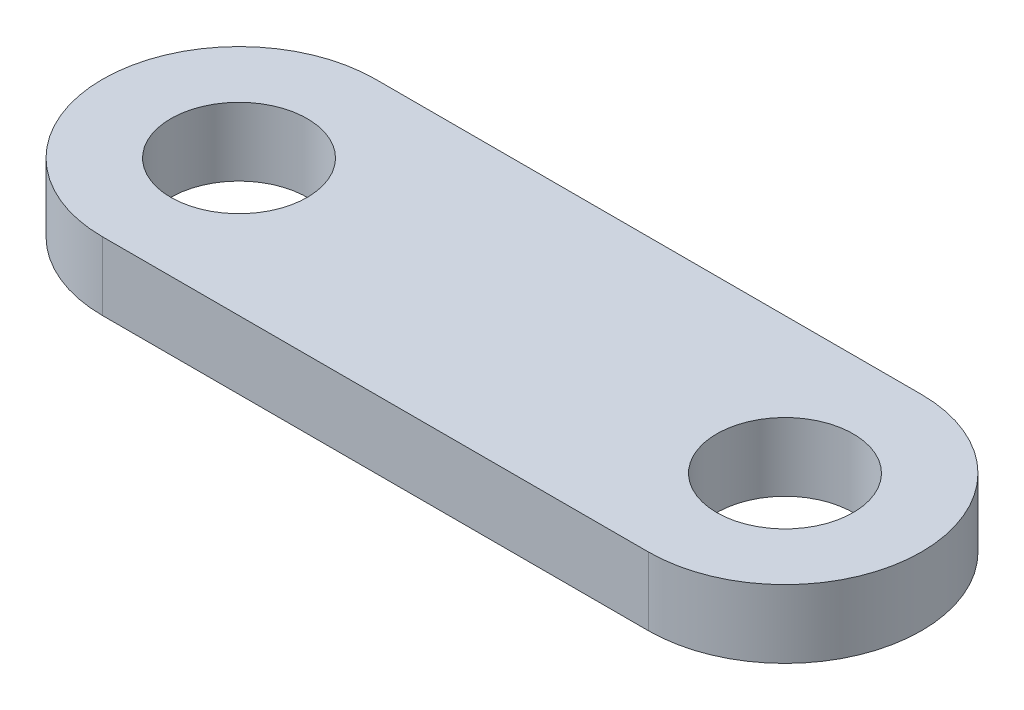
from build123d import *

# Parameters (mm, degrees)
SKETCH3_R           = 5
BOSS_EXTRUDE1_DEPTH = 5


with BuildPart() as part:
    # Sketch3 → Boss-Extrude1 (new body)
    with BuildSketch(Plane(origin=(0, 0, 0), x_dir=(1, 0, 0), z_dir=(0, 1, 0))):
        with BuildLine():
            Line((-20, 10), (20, 10))
            ThreePointArc((20, 10), (30, 0), (20, -10))
            Line((20, -10), (-20, -10))
            ThreePointArc((-20, -10), (-30, 0), (-20, 10))
        make_face()
        with Locations((-20, 0)):
            Circle(SKETCH3_R, mode=Mode.SUBTRACT)
        with Locations((20, 0)):
            Circle(SKETCH3_R, mode=Mode.SUBTRACT)
    extrude(amount=BOSS_EXTRUDE1_DEPTH)


solid = part.part
